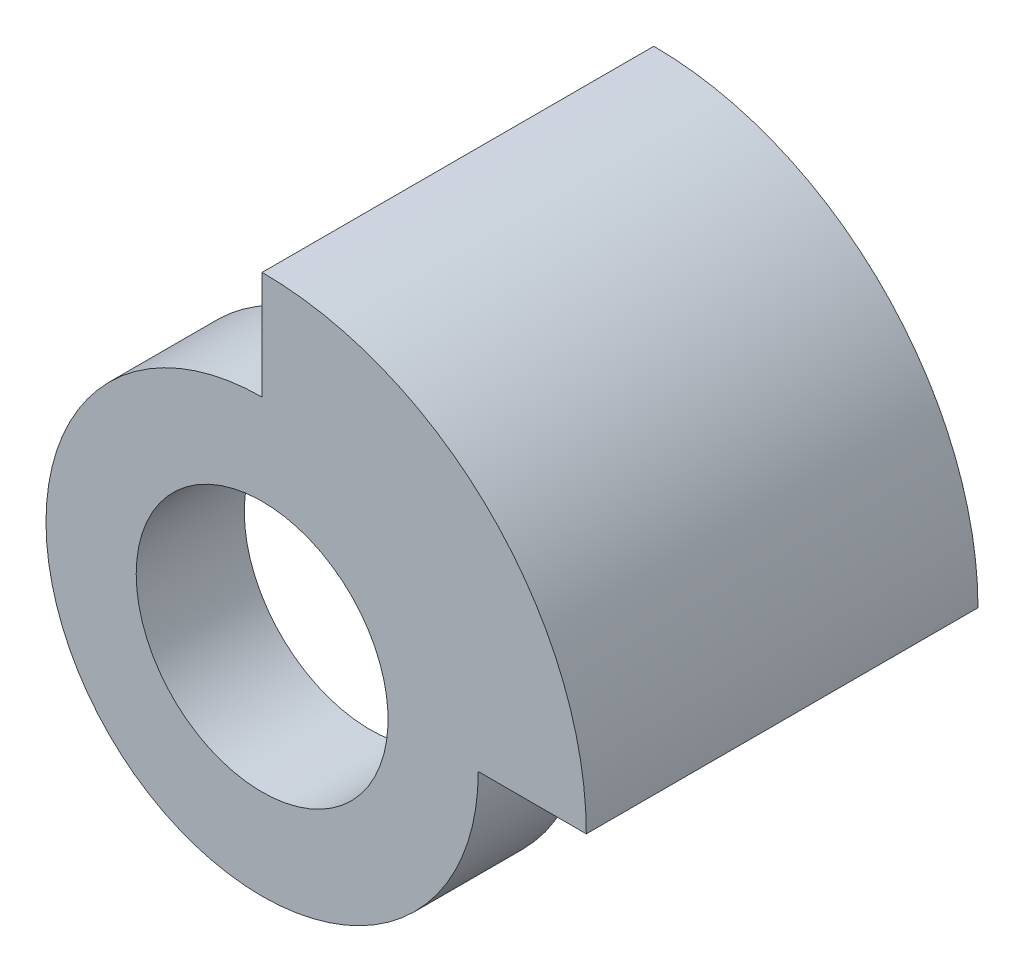
from build123d import *

# Parameters (mm, degrees)
SKETCH1_R           = 11.1
BOSS_EXTRUDE5_DEPTH = 9.525
BOSS_EXTRUDE6_DEPTH = 25


with BuildPart() as part:
    # Sketch1 → Boss-Extrude5 (new body)
    with BuildSketch(Plane.XY):
        with BuildLine():
            ThreePointArc((0, 19.051378432), (-13.47135888, -13.47135888), (19.051378432, 0))
            Line((19.051378432, 0), (28.575, 0))
            ThreePointArc((28.575, 0), (20.205576272, 20.205576272), (0, 28.575))
            Line((0, 28.575), (0, 19.051378432))
        make_face()
        with Locations(Location((0, 0, 0), (0, 0, 180))):
            Circle(SKETCH1_R, mode=Mode.SUBTRACT)
    extrude(amount=BOSS_EXTRUDE5_DEPTH)

    # Sketch2 → Boss-Extrude6 (add)
    with BuildSketch(Plane(origin=(0, 0, 0), x_dir=(-1, 0, 0), z_dir=(0, 0, -1))):
        with BuildLine():
            add(Edge.make_bspline(
                [(0, 28.575), (-21.908651484, 21.908651484), (-28.575, 0)],
                knots=[0, 0, 0, 1, 1, 1], degree=2))
            ThreePointArc((-28.575, 0), (-20.205576272, 20.205576272), (0, 28.575))
        make_face()
        with BuildLine():
            Line((0, 19.4), (0, 28.575))
            add(Edge.make_bspline(
                [(0, 28.575), (-21.908651484, 21.908651484), (-28.575, 0)],
                knots=[0, 0, 0, 1, 1, 1], degree=2))
            Line((-28.575, 0), (-19.4, 0))
            ThreePointArc((-19.4, 0), (-13.717871555, 13.717871555), (0, 19.4))
        make_face()
    extrude(amount=BOSS_EXTRUDE6_DEPTH)


solid = part.part
